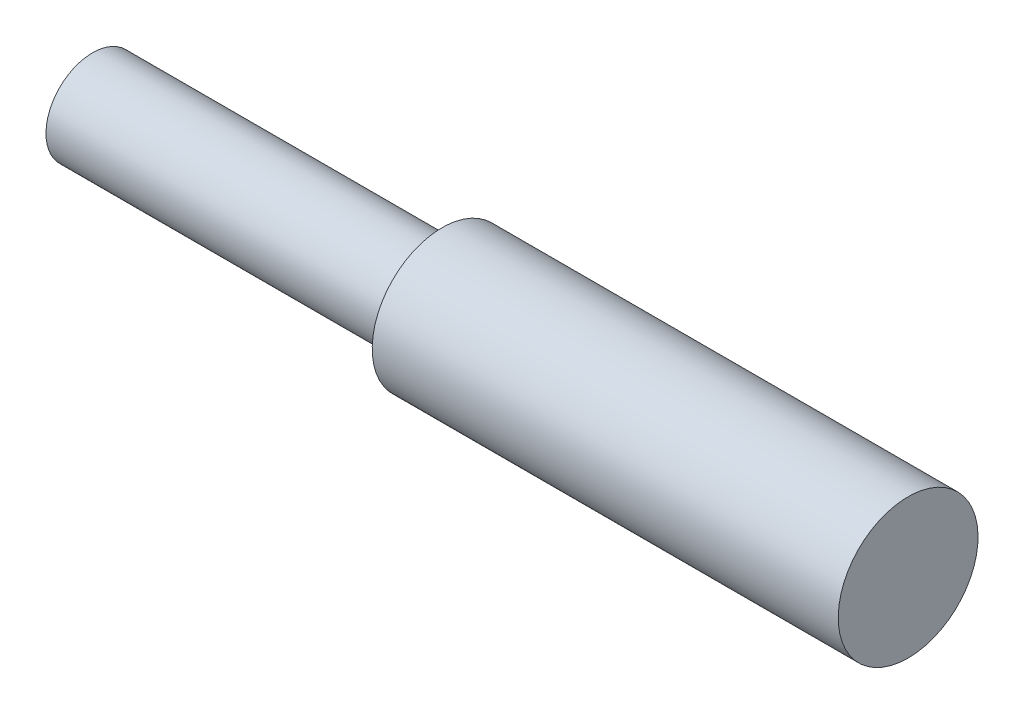
from build123d import *


with BuildPart() as part:
    # Sketch1 → Revolve1 (revolve)
    with BuildSketch(Plane(origin=(0, 0, 0), x_dir=(-1, 0, 0), z_dir=(0, 0, -1))):
        Polygon((-20, 3), (-20, 0), (15, 0), (15, 2), (0, 2), (0, 3), align=None)
    revolve(axis=Axis((20, 0, 0), (-1, 0, 0)))


solid = part.part
